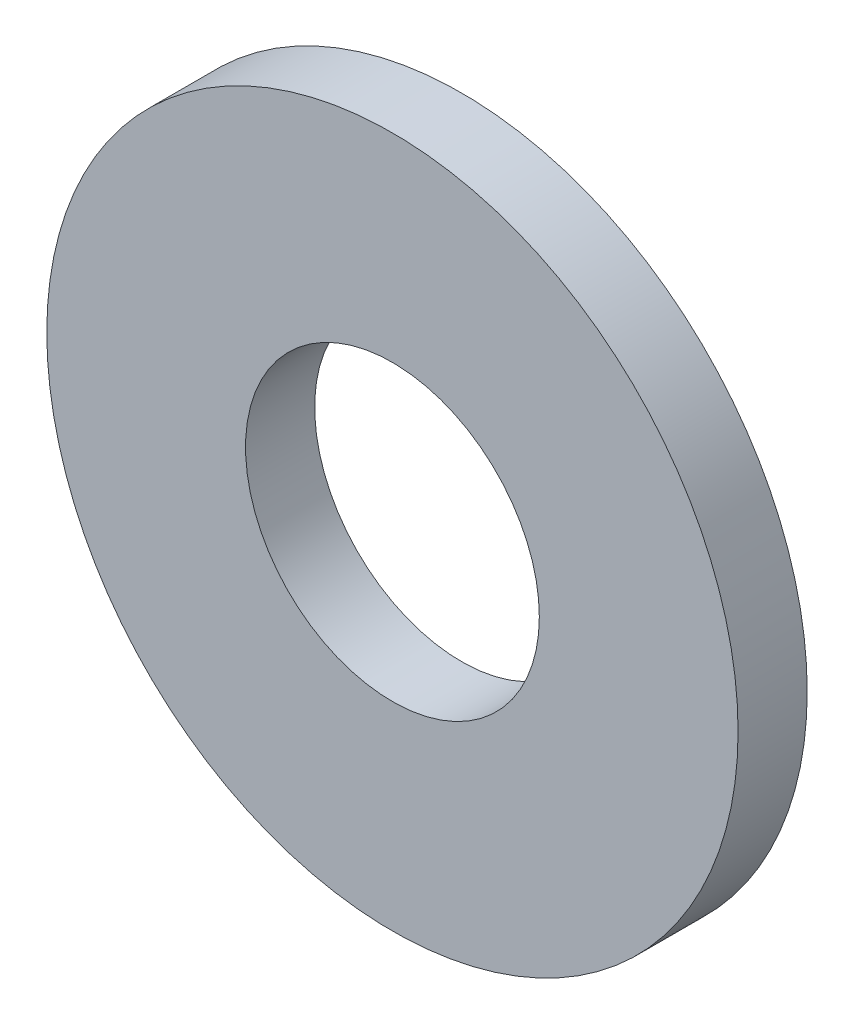
from build123d import *

# Parameters (mm, degrees)
SKETCH1_R           = 2
SKETCH1_R_2         = 0.85
BOSS_EXTRUDE1_DEPTH = 0.4


with BuildPart() as part:
    # Sketch1 → Boss-Extrude1 (new body)
    with BuildSketch(Plane.XY):
        Circle(SKETCH1_R)
        Circle(SKETCH1_R_2, mode=Mode.SUBTRACT)
    extrude(amount=BOSS_EXTRUDE1_DEPTH)


solid = part.part
